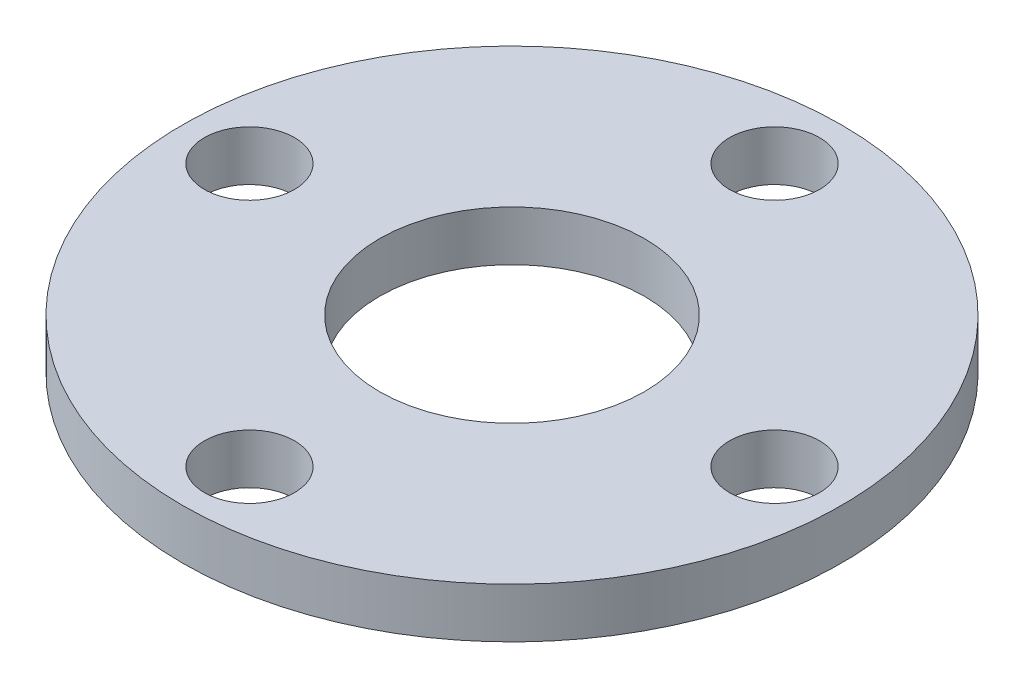
from build123d import *

# Parameters (mm, degrees)
CROQUIS1_R              = 13.18
CROQUIS1_R_2            = 5.3
SALIENTE_EXTRUIR1_DEPTH = 2
CROQUIS2_R              = 1.8
CORTAR_EXTRUIR1_DEPTH   = 2
MATRIZC1_COUNT          = 4


with BuildPart() as part:
    # Croquis1 → Saliente-Extruir1 (new body)
    with BuildSketch(Plane(origin=(0, 0, 0), x_dir=(1, 0, 0), z_dir=(0, 1, 0))):
        Circle(CROQUIS1_R)
        Circle(CROQUIS1_R_2, mode=Mode.SUBTRACT)
    extrude(amount=SALIENTE_EXTRUIR1_DEPTH)

    # Croquis2 → Cortar-Extruir1 (cut)
    with BuildSketch(Plane(origin=(0, 2, 0), x_dir=(1, 0, 0), z_dir=(0, 1, 0))):
        with Locations((10.5, 0)):
            Circle(CROQUIS2_R)
    cortar_extruir1 = extrude(amount=-CORTAR_EXTRUIR1_DEPTH, mode=Mode.SUBTRACT)

    # MatrizC1: Cortar-Extruir1 ×4 about axis
    matrizc1_axis = Axis((0, 0, 0), (0, 1, 0))
    for i in range(1, MATRIZC1_COUNT):
        add(cortar_extruir1.rotate(matrizc1_axis, i * 360 / MATRIZC1_COUNT), mode=Mode.SUBTRACT)


solid = part.part
